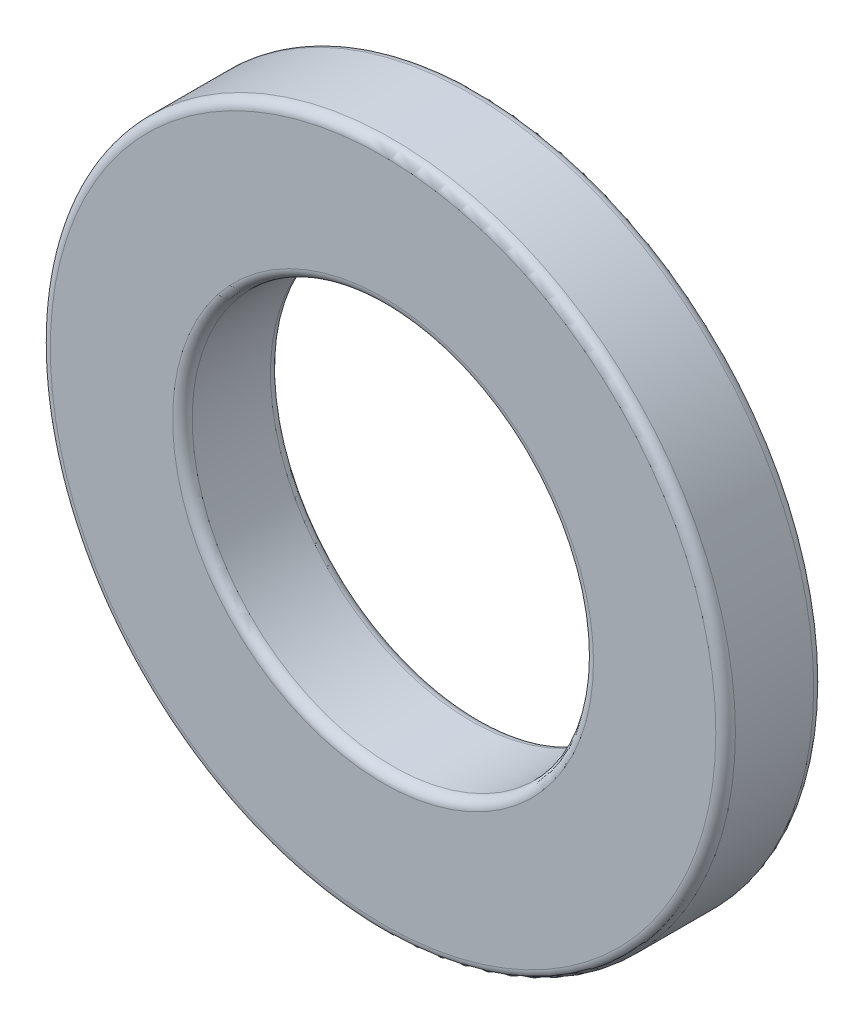
from build123d import *

# Parameters (mm, degrees)
SKETCH_1_R      = 7
SKETCH_1_R_2    = 4.1
EXTRUDE_1_DEPTH = 2
FILLET_1_R      = 0.2


with BuildPart() as part:
    # Эскиз1 → Бобышка-Вытянуть1 (new body)
    with BuildSketch(Plane.XY):
        Circle(SKETCH_1_R)
        Circle(SKETCH_1_R_2, mode=Mode.SUBTRACT)
    extrude(amount=EXTRUDE_1_DEPTH)

    # Скругление1
    fillet_1_edges = [part.edges().sort_by_distance(p)[0] for p in [
        (-7, 0, 0),
        (-7, 0, 2),
        (-4.1, 0, 0),
        (-4.1, 0, 2),
    ]]
    fillet(fillet_1_edges, radius=FILLET_1_R)


solid = part.part
